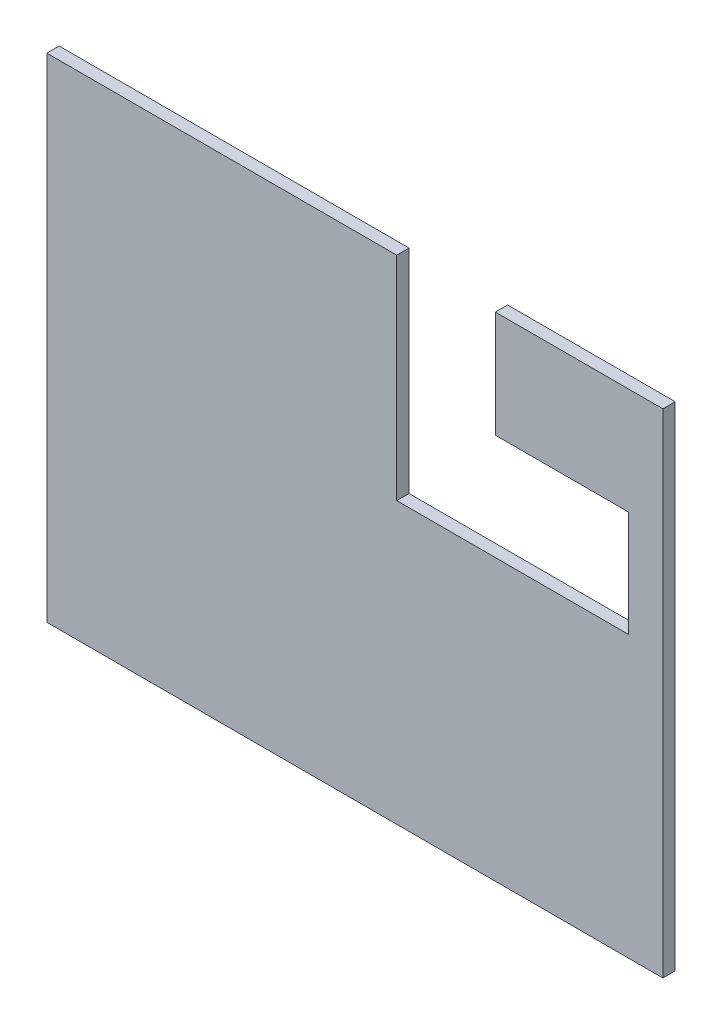
from build123d import *

# Parameters (mm, degrees)
CROQUIS1_W              = 5000
CROQUIS1_H              = 4000
SALIENTE_EXTRUIR1_DEPTH = 100
CORTAR_EXTRUIR1_DEPTH   = 100


with BuildPart() as part:
    # Croquis1 → Saliente-Extruir1 (new body)
    with BuildSketch(Plane.XY):
        with Locations((2500, 2000)):
            Rectangle(CROQUIS1_W, CROQUIS1_H)
    extrude(amount=SALIENTE_EXTRUIR1_DEPTH)

    # Croquis2 → Cortar-Extruir1 (cut)
    with BuildSketch(Plane.XY.offset(100)):
        Polygon((4720, 3135), (4720, 2275), (2840, 2275), (2840, 4000), (3640, 4000), (3640, 3135), align=None)
    extrude(amount=-CORTAR_EXTRUIR1_DEPTH, mode=Mode.SUBTRACT)


solid = part.part
